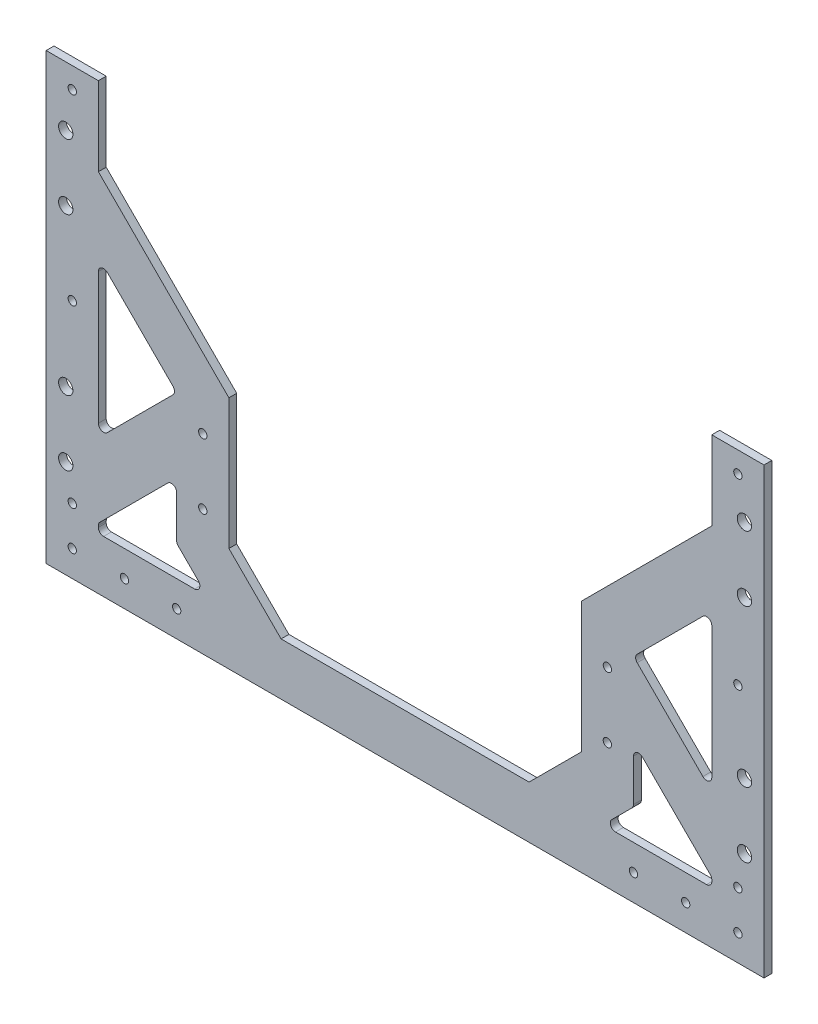
from build123d import *

# Parameters (mm, degrees)
EXTRUDE1_DEPTH     = 3
SKETCH2_R          = 2.75
SKETCH2_R_2        = 1.6
CUT_EXTRUDE1_DEPTH = 3


with BuildPart() as part:
    # Sketch1 → Extrude1 (new body)
    with BuildSketch(Plane.XY):
        Polygon((-21.510078765, 142.709593142), (-21.510078765, -27.502951786), (253.489921235, -27.502951786), (253.489921235, 142.709593142), (233.489921235, 142.709593142), (233.489921235, 112.497048214), (183.489921235, 62.497048214), (183.489921235, 12.497048214), (163.489921235, -7.502951786), (68.489921235, -7.502951786), (48.489921235, 12.497048214), (48.489921235, 62.497048214), (-1.510078765, 112.497048214), (-1.510078765, 142.709593142), align=None)
        with BuildLine():
            Line((-1.510078765, -5.502951786), (-1.510078765, -4.899921406))
            ThreePointArc((-1.510078765, -4.899921406), (-1.35783783, -4.134554541), (-0.924292327, -3.485707844))
            Line((-0.924292327, -3.485707844), (25.075707673, 22.514292156))
            ThreePointArc((25.075707673, 22.514292156), (27.2552881, 22.947837659), (28.489921235, 21.100078594))
            Line((28.489921235, 21.100078594), (28.489921235, 5.041204091))
            ThreePointArc((28.489921235, 5.041204091), (28.64216217, 4.275837226), (29.075707673, 3.626990528))
            Line((29.075707673, 3.626990528), (36.791436425, -4.088738224))
            ThreePointArc((36.791436425, -4.088738224), (37.224981928, -6.268318651), (35.377222863, -7.502951786))
            Line((35.377222863, -7.502951786), (0.489921235, -7.502951786))
            ThreePointArc((0.489921235, -7.502951786), (-0.924292327, -6.917165349), (-1.510078765, -5.502951786))
        make_face(mode=Mode.SUBTRACT)
        with BuildLine():
            Line((1.904134797, 80.798563404), (27.075707673, 55.626990528))
            ThreePointArc((27.075707673, 55.626990528), (27.66149411, 54.212776966), (27.075707673, 52.798563404))
            Line((27.075707673, 52.798563404), (1.904134797, 27.626990528))
            ThreePointArc((1.904134797, 27.626990528), (-0.27544563, 27.193445026), (-1.510078765, 29.041204091))
            Line((-1.510078765, 29.041204091), (-1.510078765, 79.384349841))
            ThreePointArc((-1.510078765, 79.384349841), (-0.27544563, 81.232108906), (1.904134797, 80.798563404))
        make_face(mode=Mode.SUBTRACT)
        with BuildLine():
            Line((233.489921235, 29.041204091), (233.489921235, 79.384349841))
            ThreePointArc((233.489921235, 79.384349841), (232.2552881, 81.232108906), (230.075707673, 80.798563404))
            Line((230.075707673, 80.798563404), (204.904134797, 55.626990528))
            ThreePointArc((204.904134797, 55.626990528), (204.31834836, 54.212776966), (204.904134797, 52.798563404))
            Line((204.904134797, 52.798563404), (230.075707673, 27.626990528))
            ThreePointArc((230.075707673, 27.626990528), (232.2552881, 27.193445026), (233.489921235, 29.041204091))
        make_face(mode=Mode.SUBTRACT)
        with BuildLine():
            Line((232.904134797, -3.485707844), (206.904134797, 22.514292156))
            ThreePointArc((206.904134797, 22.514292156), (204.72455437, 22.947837659), (203.489921235, 21.100078594))
            Line((203.489921235, 21.100078594), (203.489921235, 5.041204091))
            ThreePointArc((203.489921235, 5.041204091), (203.3376803, 4.275837226), (202.904134797, 3.626990528))
            Line((202.904134797, 3.626990528), (195.188406045, -4.088738224))
            ThreePointArc((195.188406045, -4.088738224), (194.754860542, -6.268318651), (196.602619607, -7.502951786))
            Line((196.602619607, -7.502951786), (231.489921235, -7.502951786))
            ThreePointArc((231.489921235, -7.502951786), (232.904134797, -6.917165349), (233.489921235, -5.502951786))
            Line((233.489921235, -5.502951786), (233.489921235, -4.899921406))
            ThreePointArc((233.489921235, -4.899921406), (233.3376803, -4.134554541), (232.904134797, -3.485707844))
        make_face(mode=Mode.SUBTRACT)
    extrude(amount=EXTRUDE1_DEPTH)

    # Sketch2 → Cut-Extrude1 (cut)
    with BuildSketch(Plane.XY.offset(3)):
        with Locations((-14.010076813, 119.997448214)):
            Circle(SKETCH2_R)
        with Locations((-14.010076813, 94.997448214)):
            Circle(SKETCH2_R)
        with Locations((-14.010076813, 34.997448214)):
            Circle(SKETCH2_R)
        with Locations((-14.010076813, 9.997448214)):
            Circle(SKETCH2_R)
        with Locations((-11.510078765, -2.502951786)):
            Circle(SKETCH2_R_2)
        with Locations((-11.510078765, -17.502951786)):
            Circle(SKETCH2_R_2)
        with Locations((8.489921235, -17.502951786)):
            Circle(SKETCH2_R_2)
        with Locations((28.489921235, -17.502951786)):
            Circle(SKETCH2_R_2)
        with Locations((38.489921235, 20.569514271)):
            Circle(SKETCH2_R_2)
        with Locations((38.489921235, 45.569514271)):
            Circle(SKETCH2_R_2)
        with Locations((-11.510078765, 64.709593142)):
            Circle(SKETCH2_R_2)
        with Locations((193.489923187, 45.569514271)):
            Circle(SKETCH2_R_2)
        with Locations((193.489923187, 20.569514271)):
            Circle(SKETCH2_R_2)
        with Locations((203.489923187, -17.502951786)):
            Circle(SKETCH2_R_2)
        with Locations((223.489923187, -17.502951786)):
            Circle(SKETCH2_R_2)
        with Locations((243.489923187, -17.502951786)):
            Circle(SKETCH2_R_2)
        with Locations((245.989921235, 34.997448214)):
            Circle(SKETCH2_R)
        with Locations((245.989921235, 9.997448214)):
            Circle(SKETCH2_R)
        with Locations((243.489923187, 64.709593142)):
            Circle(SKETCH2_R_2)
        with Locations((243.489923187, 134.709593142)):
            Circle(SKETCH2_R_2)
        with Locations((245.989921235, 119.997448214)):
            Circle(SKETCH2_R)
        with Locations((245.989921235, 94.997448214)):
            Circle(SKETCH2_R)
        with Locations((-11.510078765, 134.709593142)):
            Circle(SKETCH2_R_2)
        with Locations((243.489923187, -2.502951786)):
            Circle(SKETCH2_R_2)
    extrude(amount=-CUT_EXTRUDE1_DEPTH, mode=Mode.SUBTRACT)


solid = part.part
